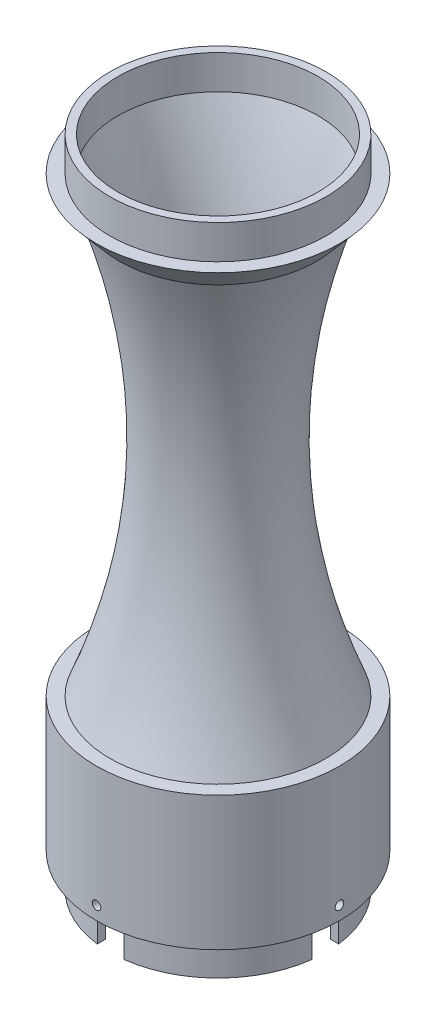
from build123d import *

# Parameters (mm, degrees)
CUT_EXTRUDE1_DEPTH = 22.7
SKETCH3_R          = 1.6
CUT_EXTRUDE2_DEPTH = 6
CIRPATTERN1_COUNT  = 4


with BuildPart() as part:
    # Sketch1 → Revolve1 (revolve)
    with BuildSketch(Plane.XY):
        with BuildLine():
            Line((0, 188.999986017), (0, 201.699986017))
            Line((0, 201.699986017), (-3, 201.699986017))
            Line((-3, 201.699986017), (-3, 188.999986017))
            Line((-3, 188.999986017), (-8, 188.999986017))
            Line((-8, 188.999986017), (0.570207018, 178.999986017))
            add(Edge.make_bspline(
                [(-3, 19.999986017), (17.518474446, 71.927940579), (18.708543453, 124.927940579), (0.570207018, 178.999986017)],
                knots=[0, 0, 0, 0, 0.942000122, 0.942000122, 0.942000122, 0.942000122], degree=3))
            Line((-3, 19.999986017), (-8, 19.999986017))
            Line((-8, 19.999986017), (-8, -30.000013983))
            Line((-8, -30.000013983), (-3, -30.000013983))
            Line((-3, -30.000013983), (-3, -42.700013983))
            Line((-3, -42.700013983), (0, -42.700013983))
            Line((0, -42.700013983), (0, -30.000013983))
            Line((0, -30.000013983), (0, 20.000038989))
            add(Edge.make_bspline(
                [(0, 20.000038989), (32.672733587, 102.687823602), (0, 188.999986017)],
                knots=[0, 0, 0, 1, 1, 1], degree=2))
        make_face()
    revolve(axis=Axis((37.402673701, -40.000005834, 0), (0, 1, 0)))

    # Sketch2 → Cut-Extrude1 (cut)
    with BuildSketch(Plane.XZ.offset(42.700013983)):
        with BuildLine():
            Line((25.405862227, 5), (-3, 5))
            Line((-3, 5), (-3, -5))
            Line((-3, -5), (25.405862227, -5))
            ThreePointArc((25.405862227, -5), (28.2123667, -9.190307001), (32.402673701, -11.996811474))
            Line((32.402673701, -11.996811474), (32.402673701, -40.402673701))
            Line((32.402673701, -40.402673701), (42.402673701, -40.402673701))
            Line((42.402673701, -40.402673701), (42.402673701, -11.996811474))
            ThreePointArc((42.402673701, -11.996811474), (46.592980702, -9.190307001), (49.399485175, -5))
            Line((49.399485175, -5), (77.805347402, -5))
            Line((77.805347402, -5), (77.805347402, 5))
            Line((77.805347402, 5), (49.399485175, 5))
            ThreePointArc((49.399485175, 5), (46.592980702, 9.190307001), (42.402673701, 11.996811474))
            Line((42.402673701, 11.996811474), (42.402673701, 40.402673701))
            Line((42.402673701, 40.402673701), (32.402673701, 40.402673701))
            Line((32.402673701, 40.402673701), (32.402673701, 11.996811474))
            ThreePointArc((32.402673701, 11.996811474), (28.2123667, 9.190307001), (25.405862227, 5))
        make_face()
    extrude(amount=-CUT_EXTRUDE1_DEPTH, mode=Mode.SUBTRACT)

    # Sketch3 → Cut-Extrude2 (cut, through all)
    with BuildSketch(Plane(origin=(-3, 0, 0), x_dir=(0, 0, -1), z_dir=(1, 0, 0))):
        with Locations((0, -25.000013983)):
            Circle(SKETCH3_R)
    cut_extrude2 = extrude(amount=-CUT_EXTRUDE2_DEPTH, mode=Mode.SUBTRACT)

    # CirPattern1: Cut-Extrude2 ×4 about axis
    cirpattern1_axis = Axis((37.402673701, 20.000038989, 0), (0, -1, 0))
    for i in range(1, CIRPATTERN1_COUNT):
        add(cut_extrude2.rotate(cirpattern1_axis, i * 360 / CIRPATTERN1_COUNT), mode=Mode.SUBTRACT)


solid = part.part
